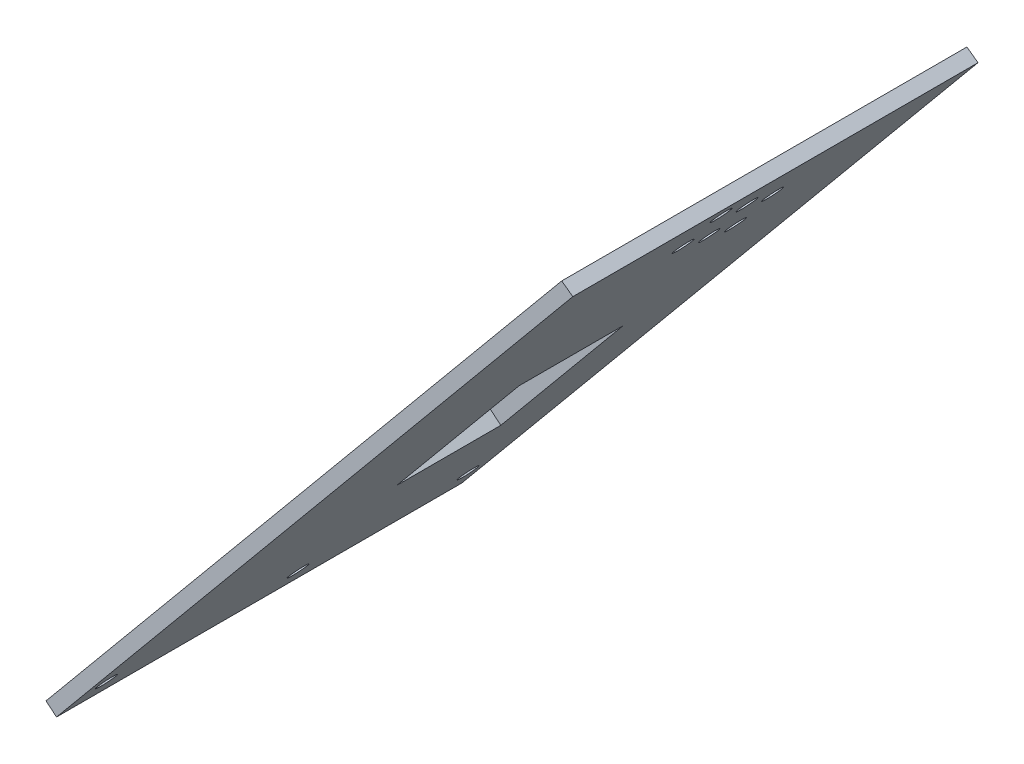
from build123d import *

# Parameters (mm, degrees)
ESTRUSIONE_SOTTILE1_DEPTH      = 37
ESTRUSIONE_SOTTILE1_DEPTH_BACK = 37
SCHIZZO2_R                     = 1.7
TAGLIO_ESTRUSIONE2_DEPTH       = 23
SCHIZZO4_W                     = 19
SCHIZZO4_H                     = 35
TAGLIO_ESTRUSIONE4_DEPTH       = 9
SCHIZZO5_R                     = 1.7
TAGLIO_ESTRUSIONE5_DEPTH       = 9
TAGLIO_ESTRUSIONE6_DEPTH       = 38
TAGLIO_ESTRUSIONE6_DEPTH_BACK  = 38


with BuildPart() as part:
    # Schizzo1 → Estrusione-Sottile1 (new body, two sides)
    with BuildSketch(Plane.XY) as estrusione_sottile1_sk:
        with BuildLine():
            Line((1.3418419, 31.371953403), (-14.62198067, 12.132505153))
            Line((-14.62198067, 12.132505153), (0, 0))
            Line((0, 0), (92.590170907, 111.588799848))
            ThreePointArc((92.590170907, 111.588799848), (116.785428363, 124.808829232), (140.980685819, 111.588799848))
            Line((140.980685819, 111.588799848), (138.876827802, 110.238325322))
            ThreePointArc((138.876827802, 110.238325322), (116.710841454, 122.30872327), (94.613803758, 110.112560659))
            Line((94.613803758, 110.112560659), (0.327562568, -3.520327082))
            Line((0.327562568, -3.520327082), (-18.142307752, 11.804942585))
            Line((-18.142307752, 11.804942585), (-0.582102925, 32.96833566))
            Line((-0.582102925, 32.96833566), (1.3418419, 31.371953403))
        make_face()
    extrude(amount=ESTRUSIONE_SOTTILE1_DEPTH)
    extrude(estrusione_sottile1_sk.sketch, amount=-ESTRUSIONE_SOTTILE1_DEPTH_BACK)

    # Schizzo2 → Taglio-Estrusione2 (cut)
    with BuildSketch(Plane(origin=(1.923944825, -1.596382257, 0), x_dir=(0, 0, -1), z_dir=(0.76957793, -0.638552903, 0))):
        with Locations((-6.552412565, 139.86942204)):
            Circle(SCHIZZO2_R)
        with Locations((-6.552412565, 129.05255699)):
            Circle(SCHIZZO2_R)
        with Locations((1.452296176, 134.71047302)):
            Circle(SCHIZZO2_R)
        with Locations((9.457004918, 129.55152401)):
            Circle(SCHIZZO2_R)
        with Locations((1.553386665, 123.82845624)):
            Circle(SCHIZZO2_R)
        with Locations((9.659185895, 118.60435549)):
            Circle(SCHIZZO2_R)
    extrude(amount=-TAGLIO_ESTRUSIONE2_DEPTH, mode=Mode.SUBTRACT)

    # Schizzo4 → Taglio-Estrusione4 (cut)
    with BuildSketch(Plane(origin=(0, 0, 0), x_dir=(0, 0, 1), z_dir=(-0.76957793, 0.638552903, 0))):
        with Locations((-7.5, 57.5)):
            Rectangle(SCHIZZO4_W, SCHIZZO4_H)
    extrude(amount=-TAGLIO_ESTRUSIONE4_DEPTH, mode=Mode.SUBTRACT)

    # Schizzo5 → Taglio-Estrusione5 (cut)
    with BuildSketch(Plane(origin=(0, 0, 0), x_dir=(0, 0, 1), z_dir=(-0.76957793, 0.638552903, 0))):
        with Locations((33, 5.5)):
            Circle(SCHIZZO5_R)
        with Locations((-33, 5.5)):
            Circle(SCHIZZO5_R)
        with Locations((-2, 5.5)):
            Circle(SCHIZZO5_R)
    extrude(amount=-TAGLIO_ESTRUSIONE5_DEPTH, mode=Mode.SUBTRACT)

    # Schizzo6 → Taglio-Estrusione6 (cut, two sides)
    with BuildSketch(Plane.XY) as taglio_estrusione6_sk:
        Polygon((0, 0), (-2.515119204, -3.03119792), (-24.654006172, 16.441396342), (100.036117815, 158.204765097), (192.825186497, 76.590730526), (160.291370892, 39.602209292), (94.613803758, 110.112560659), (92.590170907, 111.588799848), (78.649981188, 114.87986373), align=None)
    extrude(amount=TAGLIO_ESTRUSIONE6_DEPTH, mode=Mode.SUBTRACT)
    extrude(taglio_estrusione6_sk.sketch, amount=-TAGLIO_ESTRUSIONE6_DEPTH_BACK, mode=Mode.SUBTRACT)


solid = part.part
